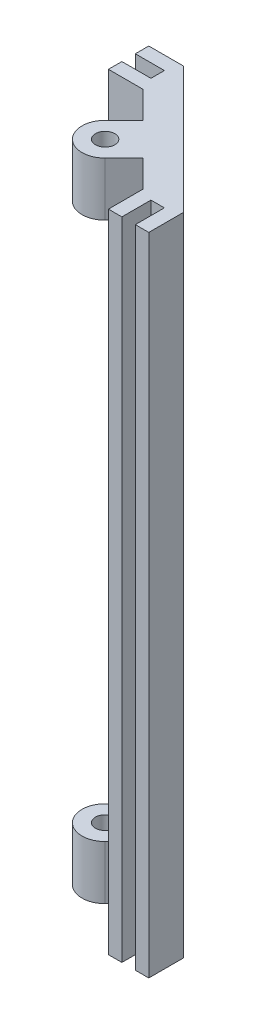
from build123d import *

# Parameters (mm, degrees)
SKETCH1_R           = 2.286
BOSS_EXTRUDE1_DEPTH = 152.4
SKETCH2_W           = 10.922
SKETCH2_H           = 127
CUT_EXTRUDE1_DEPTH  = 11.811
SKETCH3_W           = 6.35
SKETCH3_H           = 127
BOSS_EXTRUDE2_DEPTH = 1.27


with BuildPart() as part:
    # Sketch1 → Boss-Extrude1 (new body)
    with BuildSketch(Plane(origin=(0, 0, 0), x_dir=(1, 0, 0), z_dir=(0, 1, 0))):
        with BuildLine():
            Line((38.1, 0), (38.1, 8.209871939))
            Line((38.1, 8.209871939), (8.209871939, 38.1))
            Line((8.209871939, 38.1), (0, 38.1))
            Line((0, 38.1), (0, 34.925))
            Line((0, 34.925), (6.858, 34.925))
            Line((6.858, 34.925), (6.858, 31.75))
            Line((6.858, 31.75), (0, 31.75))
            Line((0, 31.75), (0, 28.575))
            Line((0, 28.575), (8.209871939, 28.575))
            Line((8.209871939, 28.575), (14.530925838, 22.253946102))
            Line((14.530925838, 22.253946102), (10.040797777, 17.763818041))
            ThreePointArc((10.040797777, 17.763818041), (10.040797777, 10.040797777), (17.763818041, 10.040797777))
            Line((17.763818041, 10.040797777), (22.253946102, 14.530925838))
            Line((22.253946102, 14.530925838), (28.575, 8.209871939))
            Line((28.575, 8.209871939), (28.575, 0))
            Line((28.575, 0), (31.75, 0))
            Line((31.75, 0), (31.75, 6.858))
            Line((31.75, 6.858), (34.925, 6.858))
            Line((34.925, 6.858), (34.925, 0))
            Line((34.925, 0), (38.1, 0))
        make_face()
        with Locations((13.902307909, 13.902307909)):
            Circle(SKETCH1_R, mode=Mode.SUBTRACT)
    extrude(amount=BOSS_EXTRUDE1_DEPTH)

    # Sketch2 → Cut-Extrude1 (cut)
    with BuildSketch(Plane(origin=(18.39243597, 0, -18.39243597), x_dir=(0.707106781, 0, 0.707106781), z_dir=(-0.707106781, 0, 0.707106781))):
        with Locations((0, 76.2)):
            Rectangle(SKETCH2_W, SKETCH2_H)
    extrude(amount=CUT_EXTRUDE1_DEPTH, mode=Mode.SUBTRACT)

    # Sketch3 → Boss-Extrude2 (add)
    with BuildSketch(Plane(origin=(18.39243597, 0, -18.39243597), x_dir=(0.707106781, 0, 0.707106781), z_dir=(-0.707106781, 0, 0.707106781))):
        with Locations((0, 76.2)):
            Rectangle(SKETCH3_W, SKETCH3_H)
    extrude(amount=BOSS_EXTRUDE2_DEPTH)


solid = part.part
